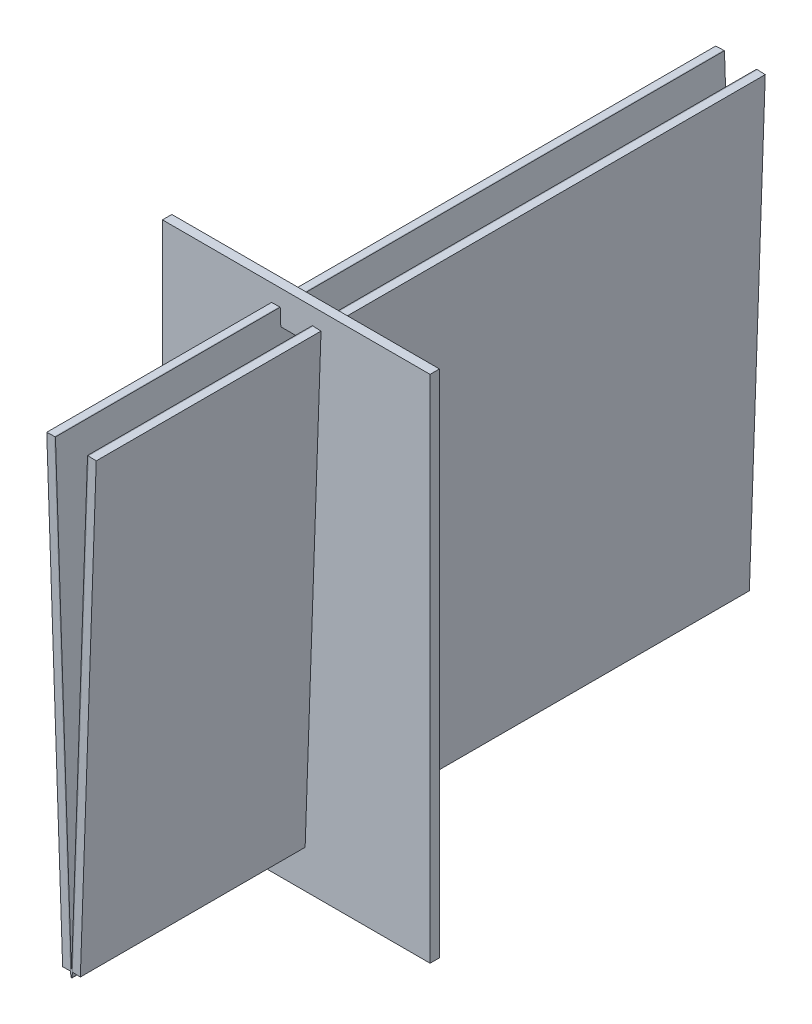
from build123d import *

# Parameters (mm, degrees)
BOSS_EXTRUDE1_DEPTH             = 100
BOSS_EXTRUDE1_2_DEPTH           = 100
BOSS_EXTRUDE2_REACH             = 170.988
BOSS_EXTRUDE2_DIRECTION_2_REACH = 170.988
SKETCH5_W                       = 80
SKETCH5_H                       = 152.464323179
BOSS_EXTRUDE3_DEPTH             = 2.8


with BuildPart() as part:
    # Sketch2 → Boss-Extrude1 (new, symmetric)
    with BuildSketch(Plane.XY):
        Polygon((-0.25, 0), (-5, 136.022203094), (-7.398537985, 135.938444302), (-2.648537985, -0.083758792), align=None)
    extrude(amount=BOSS_EXTRUDE1_DEPTH, both=True)


with BuildPart() as body_2:
    # Sketch2 → Boss-Extrude1 2 (new, symmetric)
    with BuildSketch(Plane.XY):
        Polygon((0.25, 0), (5, 136.022203094), (7.398537985, 135.938444302), (2.648537985, -0.083758792), align=None)
    extrude(amount=BOSS_EXTRUDE1_2_DEPTH, both=True)


with BuildPart() as body_3:

    # Boss-Extrude2: up to this face of the body (flat: up to its plane)
    boss_extrude2_end = Plane(part.part.faces().sort_by_distance((-3.824268992, 67.969222151, 100))[0])
    # Sketch4 → Boss-Extrude2 (new, up to the picked face)
    with BuildSketch(Plane.XY, mode=Mode.PRIVATE) as boss_extrude2_sk1:
        with BuildLine():
            Line((-5, 136.022203094), (-0.199878165, -1.43530155))
            ThreePointArc((-0.199878165, -1.43530155), (0, -1.628321651), (0.199878165, -1.43530155))
            Line((0.199878165, -1.43530155), (5, 136.022203094))
            Line((5, 136.022203094), (4.800121835, 136.029182993))
            Line((4.800121835, 136.029182993), (0, -1.428321651))
            Line((0, -1.428321651), (-4.800121835, 136.029182993))
            Line((-4.800121835, 136.029182993), (-5, 136.022203094))
        make_face()
    boss_extrude2_tool1 = split(extrude(boss_extrude2_sk1.sketch, amount=BOSS_EXTRUDE2_REACH, mode=Mode.PRIVATE), bisect_by=boss_extrude2_end, keep=Keep.BOTH, mode=Mode.PRIVATE)
    add(boss_extrude2_tool1.solids().sort_by(Axis((2.462003, 67.298268, 0), (0, 0, 1)))[0])


    # Boss-Extrude2 direction 2: up to this face of the body (flat: up to its plane)
    boss_extrude2_direction_2_end = Plane(part.part.faces().sort_by_distance((-3.824268992, 67.969222151, -100))[0])
    # Sketch4 → Boss-Extrude2 direction 2 (add, up to the picked face)
    with BuildSketch(Plane.XY, mode=Mode.PRIVATE) as boss_extrude2_direction_2_sk1:
        with BuildLine():
            Line((-5, 136.022203094), (-0.199878165, -1.43530155))
            ThreePointArc((-0.199878165, -1.43530155), (0, -1.628321651), (0.199878165, -1.43530155))
            Line((0.199878165, -1.43530155), (5, 136.022203094))
            Line((5, 136.022203094), (4.800121835, 136.029182993))
            Line((4.800121835, 136.029182993), (0, -1.428321651))
            Line((0, -1.428321651), (-4.800121835, 136.029182993))
            Line((-4.800121835, 136.029182993), (-5, 136.022203094))
        make_face()
    boss_extrude2_direction_2_tool1 = split(extrude(boss_extrude2_direction_2_sk1.sketch, amount=-BOSS_EXTRUDE2_DIRECTION_2_REACH, mode=Mode.PRIVATE), bisect_by=boss_extrude2_direction_2_end, keep=Keep.BOTH, mode=Mode.PRIVATE)
    add(boss_extrude2_direction_2_tool1.solids().sort_by(Axis((2.462003, 67.298268, 0), (0, 0, -1)))[0])


with BuildPart() as body_4:
    # Sketch5 → Boss-Extrude3 (new body)
    with BuildSketch(Plane.XY.offset(30)):
        with Locations((0, 64.797021403)):
            Rectangle(SKETCH5_W, SKETCH5_H)
        Polygon((-4.800121835, 136.029182993), (-4.625517987, 131.029182993), (4.625517987, 131.029182993), (4.800121835, 136.029182993), (7.398537985, 135.938444302), (2.900792305, 7.139859814), (-2.900792305, 7.139859814), (-7.398537985, 135.938444302), align=None, mode=Mode.SUBTRACT)
    extrude(amount=BOSS_EXTRUDE3_DEPTH)


solid = Compound([part.part, body_2.part, body_3.part, body_4.part])
